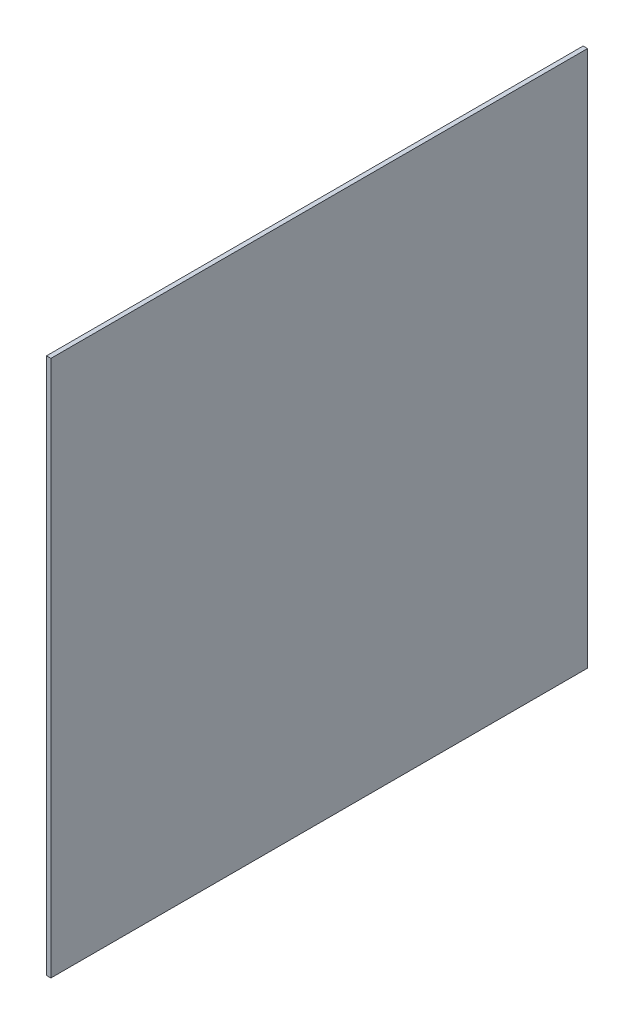
from build123d import *

# Parameters (mm, degrees)
SKETCH1_W           = 579.4375
SKETCH1_H           = 579.4375
BOSS_EXTRUDE1_DEPTH = 4.7625


with BuildPart() as part:
    # Sketch1 → Boss-Extrude1 (new body)
    with BuildSketch(Plane(origin=(0, 0, 0), x_dir=(0, 0, -1), z_dir=(1, 0, 0))):
        Rectangle(SKETCH1_W, SKETCH1_H)
    extrude(amount=BOSS_EXTRUDE1_DEPTH)


solid = part.part
